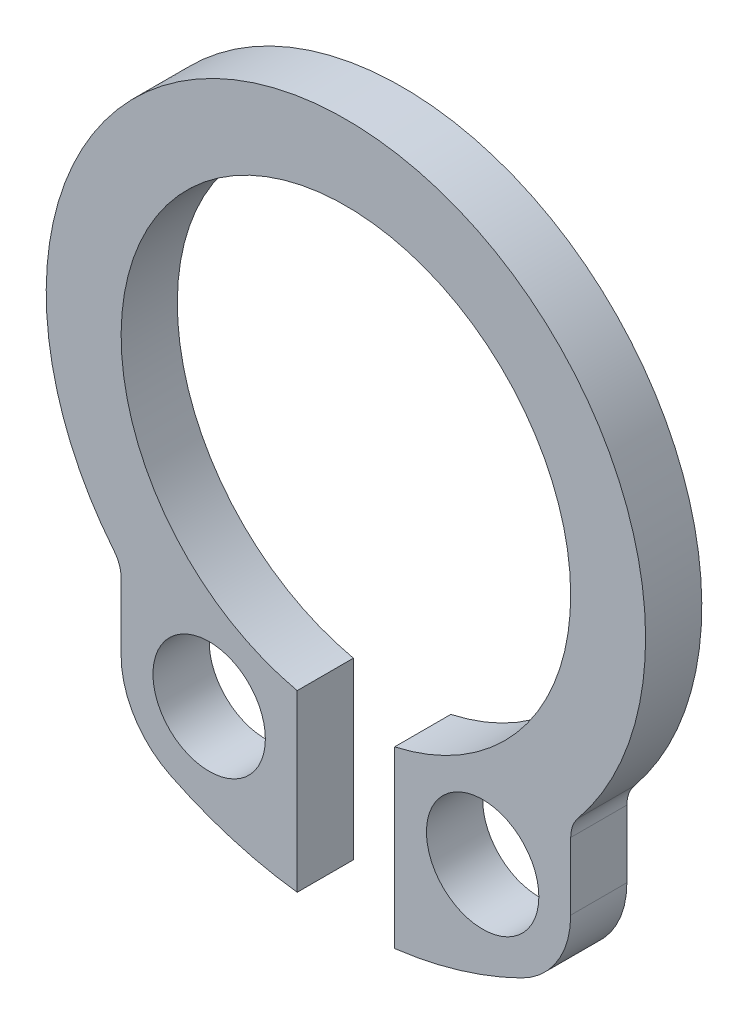
from build123d import *

# Parameters (mm, degrees)
ESQUISSE1_R          = 0.75
BASE_EXTRUSION_DEPTH = 0.75


with BuildPart() as part:
    # Esquisse1 → Base-Extrusion (new body)
    with BuildSketch(Plane.XY):
        with BuildLine():
            Line((-0.397780374, -1.603259809), (-0.397780374, 0.727993756))
            ThreePointArc((-0.397780374, 0.727993756), (0.252219626, 6.656730686), (0.902219626, 0.727993756))
            Line((0.902219626, 0.727993756), (0.902219626, -1.603259809))
            ThreePointArc((0.902219626, -1.603259809), (1.770943156, -1.421012793), (2.597068111, -1.096340488))
            ThreePointArc((2.597068111, -1.096340488), (3.075079078, -0.662997893), (3.252219626, -0.042593577))
            Line((3.252219626, -0.042593577), (3.252219626, 0.855261182))
            ThreePointArc((3.252219626, 0.855261182), (3.276946529, 0.998112319), (3.348249966, 1.124341027))
            ThreePointArc((3.348249966, 1.124341027), (0.252219626, 7.656530837), (-2.843810714, 1.124341027))
            ThreePointArc((-2.843810714, 1.124341027), (-2.772507276, 0.998112319), (-2.747780374, 0.855261182))
            Line((-2.747780374, 0.855261182), (-2.747780374, -0.042593577))
            ThreePointArc((-2.747780374, -0.042593577), (-2.570639825, -0.662997893), (-2.092628859, -1.096340488))
            ThreePointArc((-2.092628859, -1.096340488), (-1.266503904, -1.421012793), (-0.397780374, -1.603259809))
        make_face()
        with Locations((-1.572780374, -0.042593577)):
            Circle(ESQUISSE1_R, mode=Mode.SUBTRACT)
        with Locations((2.077219626, -0.042593577)):
            Circle(ESQUISSE1_R, mode=Mode.SUBTRACT)
    extrude(amount=BASE_EXTRUSION_DEPTH)


solid = part.part
